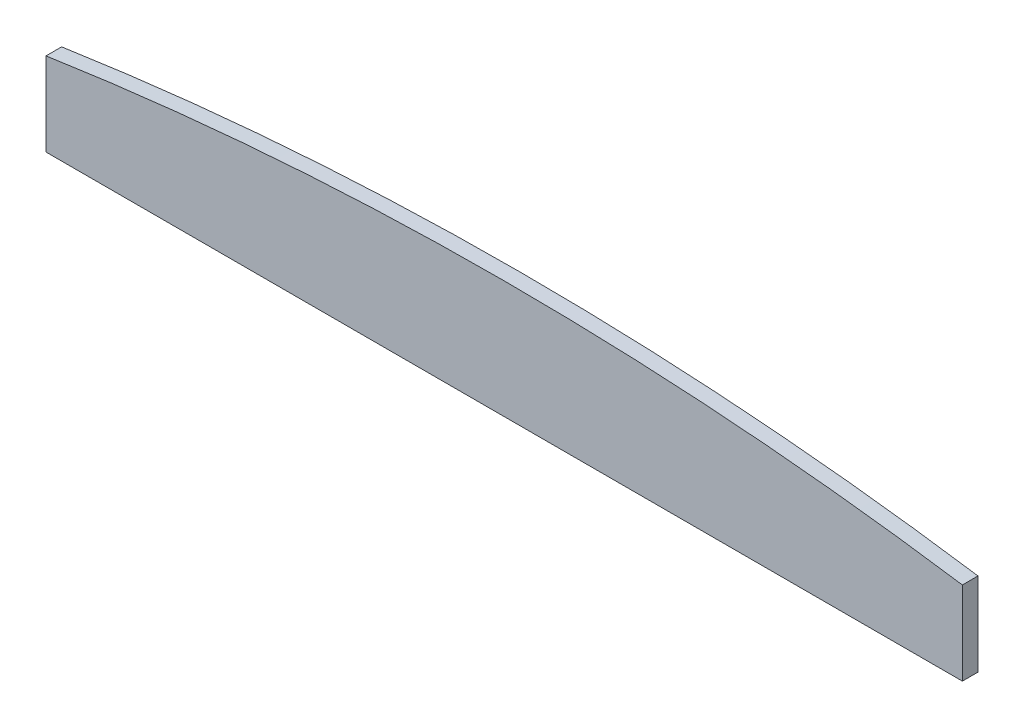
from build123d import *

# Parameters (mm, degrees)
SKETCH1_W           = 117.4
SKETCH1_H           = 2
BOSS_EXTRUDE1_DEPTH = 16
CUT_EXTRUDE1_DEPTH  = 20


with BuildPart() as part:
    # Sketch1 → Boss-Extrude1 (new body)
    with BuildSketch(Plane(origin=(0, 0, 0), x_dir=(1, 0, 0), z_dir=(0, 1, 0))):
        Rectangle(SKETCH1_W, SKETCH1_H)
    extrude(amount=BOSS_EXTRUDE1_DEPTH)

    # Sketch2 → Cut-Extrude1 (cut)
    with BuildSketch(Plane.XY.offset(1)):
        with BuildLine():
            Line((-58.7, 10.674682783), (-58.7, 16))
            Line((-58.7, 16), (58.7, 16))
            Line((58.7, 16), (58.7, 10.674682783))
            ThreePointArc((58.7, 10.674682783), (0, 15.063581336), (-58.7, 10.674682783))
        make_face()
    extrude(amount=-CUT_EXTRUDE1_DEPTH, mode=Mode.SUBTRACT)


solid = part.part
